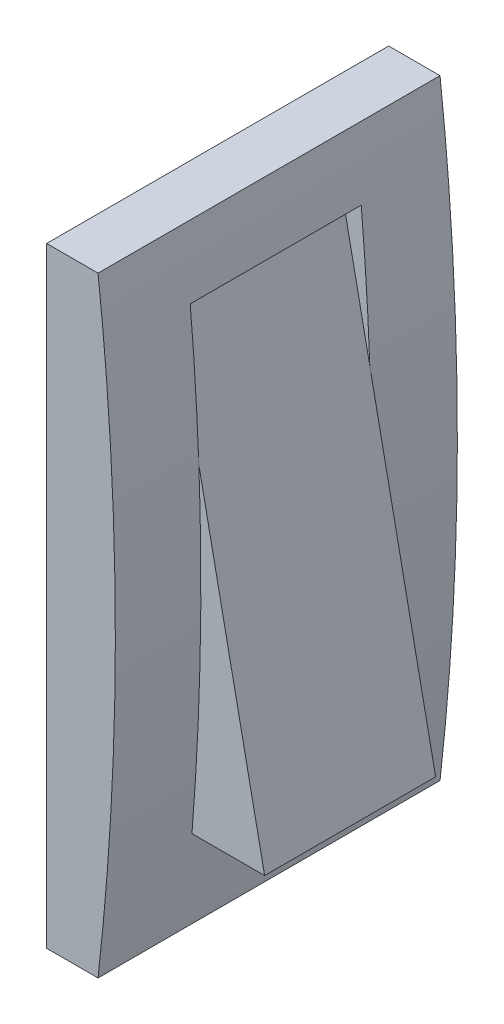
from build123d import *

# Parameters (mm, degrees)
BOSS_EXTRUDE1_DEPTH      = 20
BOSS_EXTRUDE1_DEPTH_BACK = 20
CUT_EXTRUDE1_DEPTH       = 10
CUT_EXTRUDE1_DEPTH_BACK  = 10
SKETCH4_W                = 10.912387574
SKETCH4_H                = 53.553398504
BOSS_EXTRUDE2_DEPTH      = 10
BOSS_EXTRUDE2_DEPTH_BACK = 10


with BuildPart() as part:
    # Sketch2 → Boss-Extrude1 (new, two sides: drawn at the far end of the back side and taken through both)
    with BuildSketch(Plane.XY.offset(-BOSS_EXTRUDE1_DEPTH_BACK)):
        with BuildLine():
            Line((0, -35.697454944), (0, 35.697454944))
            Line((0, 35.697454944), (6.009448328, 35.697454944))
            add(Edge.make_bspline(
                [(6.009448328, 35.697454944), (10.056825281, 0), (6.009448328, -35.697454944)],
                knots=[0, 0, 0, 1, 1, 1], degree=2))
            Line((6.009448328, -35.697454944), (0, -35.697454944))
        make_face()
    extrude(amount=BOSS_EXTRUDE1_DEPTH + BOSS_EXTRUDE1_DEPTH_BACK)

    # Sketch4 → Cut-Extrude1 (cut, two sides: drawn at the far end of the back side and taken through both)
    with BuildSketch(Plane.XY.offset(-CUT_EXTRUDE1_DEPTH_BACK)):
        with Locations((10.034480552, 1.197125595)):
            Rectangle(SKETCH4_W, SKETCH4_H)
    extrude(amount=CUT_EXTRUDE1_DEPTH + CUT_EXTRUDE1_DEPTH_BACK, mode=Mode.SUBTRACT)

    # Sketch3 → Boss-Extrude2 (add, two sides: drawn at the far end of the back side and taken through both)
    with BuildSketch(Plane.XY.offset(-BOSS_EXTRUDE2_DEPTH_BACK)):
        Polygon((4.578286765, 27.973824847), (4.578286765, -25.579573657), (15.490674339, -25.579573657), align=None)
    extrude(amount=BOSS_EXTRUDE2_DEPTH + BOSS_EXTRUDE2_DEPTH_BACK)


solid = part.part
